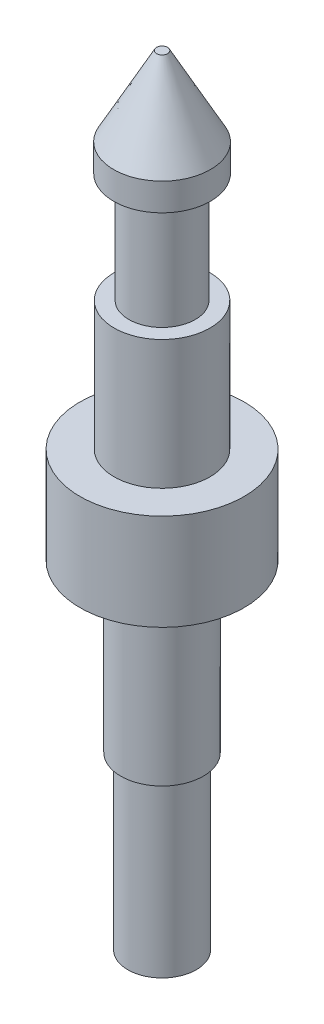
from build123d import *


with BuildPart() as part:
    # Sketch1 → Revolve1 (revolve)
    with BuildSketch(Plane.XY, mode=Mode.PRIVATE) as revolve1_sk:
        Polygon((0, 0), (1.9812, 0), (1.9812, 9.8806), (2.38125, 9.8806), (2.38125, 19.4818), (4.7371, 19.4818), (4.7371, 25.0444), (2.7686, 25.0444), (2.7686, 32.4866), (1.9177, 32.4866), (1.9177, 38.8366), (2.794, 38.8366), (2.794, 40.4241), (0.3175, 44.9834), (0, 44.9834), align=None)
    revolve(revolve1_sk.sketch.rotate(Axis((0, 0, 0), (0, 1, 0)), 90), axis=Axis((0, 0, 0), (0, 1, 0)))  # turned: the seam where the file's is


solid = part.part
